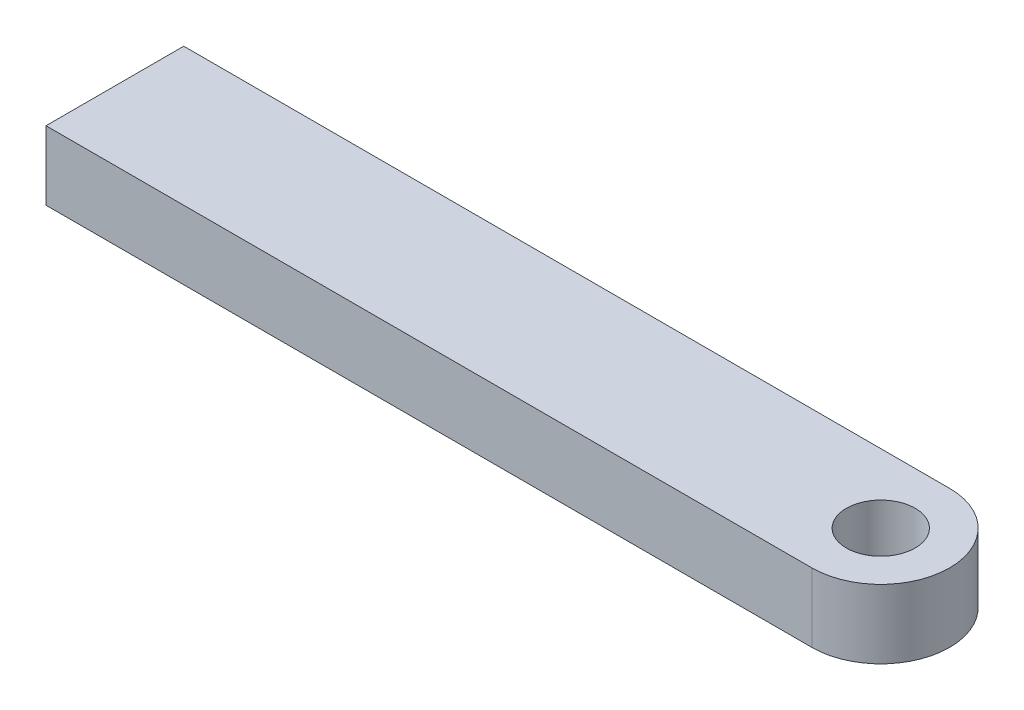
from build123d import *

# Parameters (mm, degrees)
ESQUISSE1_R                     = 2.5
BOSS_EXTRU_1_DEPTH              = 2.5
TROU_TARAUD_M3X0_51_D           = 2.5
TROU_TARAUD_M3X0_51_DEPTH       = 12.5
TROU_TARAUD_M3X0_51_CSINK_D     = 3.05
TROU_TARAUD_M3X0_51_CSINK_ANGLE = 90
TROU_TARAUD_M3X0_51_TIP         = 0.751075774


with BuildPart() as part:
    # Esquisse1 → Boss.-Extru.1 (new body, symmetric)
    with BuildSketch(Plane(origin=(0, 0, 0), x_dir=(1, 0, 0), z_dir=(0, 1, 0))):
        with BuildLine():
            Line((-55.6, -5), (0, -5))
            ThreePointArc((0, -5), (5, 0), (0, 5))
            Line((0, 5), (-55.6, 5))
            Line((-55.6, 5), (-55.6, -5))
        make_face()
        Circle(ESQUISSE1_R, mode=Mode.SUBTRACT)
    extrude(amount=BOSS_EXTRU_1_DEPTH, both=True)

    # Trou taraudé M3x0.51
    with Locations(Plane.ZY.offset(55.6)):
        with Locations((0, -0.25)):
            CounterSinkHole(TROU_TARAUD_M3X0_51_D / 2, TROU_TARAUD_M3X0_51_CSINK_D / 2, depth=TROU_TARAUD_M3X0_51_DEPTH, counter_sink_angle=TROU_TARAUD_M3X0_51_CSINK_ANGLE)
            with Locations((0, 0, -(TROU_TARAUD_M3X0_51_DEPTH + TROU_TARAUD_M3X0_51_TIP / 2))):  # 118° drill point
                Cone(0, TROU_TARAUD_M3X0_51_D / 2, TROU_TARAUD_M3X0_51_TIP, mode=Mode.SUBTRACT)


solid = part.part
